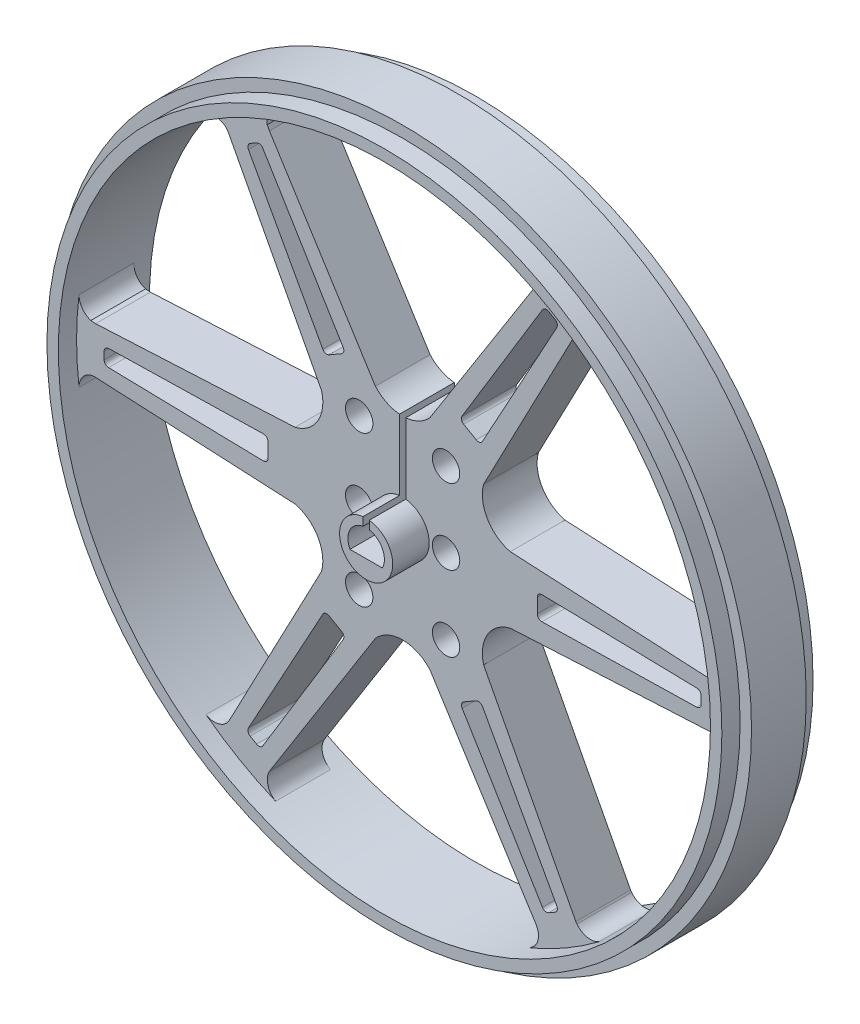
from build123d import *

# Parameters (mm, degrees)
Y_KSEKLIK_EKSTR_ZYON5_DEPTH      = 5
Y_KSEKLIK_EKSTR_ZYON5_DEPTH_BACK = 5
IZIM1_R                          = 37
Y_KSEKLIK_EKSTR_ZYON6_DEPTH      = 3
Y_KSEKLIK_EKSTR_ZYON6_DEPTH_BACK = 3
IZIM1_13_R                       = 38.25
IZIM1_13_R_2                     = 37
Y_KSEKLIK_EKSTR_ZYON7_DEPTH      = 3
Y_KSEKLIK_EKSTR_ZYON7_DEPTH_BACK = 3
IZIM1_14_R                       = 1.5
Y_KSEKLIK_EKSTR_ZYON8_DEPTH      = 7
Y_KSEKLIK_EKSTR_ZYON8_DEPTH_BACK = 3


with BuildPart() as part:
    # Çizim1 → Yükseklik-Ekstrüzyon5 (new, two sides: drawn at the far end of the back side and taken through both)
    with BuildSketch(Plane.XY.offset(-Y_KSEKLIK_EKSTR_ZYON5_DEPTH_BACK)):
        Circle(IZIM1_R)
        with BuildLine():
            ThreePointArc((-13.92488883, 32.926584565), (0, 35.75), (13.92488883, 32.926584565))
            ThreePointArc((13.92488883, 32.926584565), (17.875, 30.960408185), (21.552814278, 28.522599754))
            ThreePointArc((21.552814278, 28.522599754), (30.960408185, 17.875), (35.477703108, 4.403984811))
            ThreePointArc((35.477703108, 4.403984811), (35.681860841, 2.206197397), (35.75, 0))
            ThreePointArc((35.75, 0), (35.681860841, -2.206197397), (35.477703108, -4.403984811))
            ThreePointArc((35.477703108, -4.403984811), (30.960408185, -17.875), (21.552814278, -28.522599754))
            ThreePointArc((21.552814278, -28.522599754), (17.875, -30.960408185), (13.92488883, -32.926584565))
            ThreePointArc((13.92488883, -32.926584565), (0, -35.75), (-13.92488883, -32.926584565))
            ThreePointArc((-13.92488883, -32.926584565), (-17.875, -30.960408185), (-21.552814278, -28.522599754))
            ThreePointArc((-21.552814278, -28.522599754), (-30.960408185, -17.875), (-35.477703108, -4.403984811))
            ThreePointArc((-35.477703108, -4.403984811), (-35.75, 0), (-35.477703108, 4.403984811))
            ThreePointArc((-35.477703108, 4.403984811), (-30.960408185, 17.875), (-21.552814278, 28.522599754))
            ThreePointArc((-21.552814278, 28.522599754), (-17.875, 30.960408185), (-13.92488883, 32.926584565))
        make_face(mode=Mode.SUBTRACT)
    extrude(amount=Y_KSEKLIK_EKSTR_ZYON5_DEPTH + Y_KSEKLIK_EKSTR_ZYON5_DEPTH_BACK)

    # Çizim1<13> → Yükseklik-Ekstrüzyon6 (add, two sides: drawn at the far end of the back side and taken through both)
    with BuildSketch(Plane.XY.offset(-Y_KSEKLIK_EKSTR_ZYON6_DEPTH_BACK)):
        Circle(IZIM1_13_R)
        Circle(IZIM1_13_R_2, mode=Mode.SUBTRACT)
    extrude(amount=Y_KSEKLIK_EKSTR_ZYON6_DEPTH + Y_KSEKLIK_EKSTR_ZYON6_DEPTH_BACK)

    # Çizim1<14> → Yükseklik-Ekstrüzyon7 (add, two sides: drawn at the far end of the back side and taken through both)
    with BuildSketch(Plane.XY.offset(-Y_KSEKLIK_EKSTR_ZYON7_DEPTH_BACK)):
        with BuildLine():
            Line((0.345332455, 10.619791473), (0.345332455, 8.211364581))
            Line((0.345332455, 8.211364581), (0.345332455, 2.892483792))
            ThreePointArc((0.345332455, 2.892483792), (2.178494802, 1.93387626), (2.913025402, 0))
            ThreePointArc((2.913025402, 0), (-1.934432099, -2.17800125), (-0.343856219, 2.892659657))
            Line((-0.343856219, 2.892659657), (-0.341141708, 8.211536302))
            Line((-0.341141708, 8.211536302), (-0.339912555, 10.619966332))
            ThreePointArc((-0.339912555, 10.619966332), (-1.789622614, 11.029720322), (-2.984950797, 11.946643504))
            Line((-2.984950797, 11.946643504), (-14.607897055, 30.387938553))
            Line((-14.607897055, 30.387938553), (-14.847878363, 30.848411366))
            ThreePointArc((-14.847878363, 30.848411366), (-14.740281438, 32.044676397), (-13.92488883, 32.926584565))
            ThreePointArc((-13.92488883, 32.926584565), (-17.875, 30.960408185), (-21.552814278, 28.522599754))
            ThreePointArc((-21.552814278, 28.522599754), (-20.401800041, 28.78442387), (-19.324525803, 28.301862102))
            Line((-19.324525803, 28.301862102), (-19.045735303, 27.863795787))
            Line((-19.045735303, 27.863795787), (-8.886868167, 8.577081355))
            ThreePointArc((-8.886868167, 8.577081355), (-9.303777514, 5.496482546), (-11.800782256, 3.644761794))
            Line((-11.800782256, 3.644761794), (-33.653555768, 2.549643924))
            Line((-33.653555768, 2.549643924), (-34.19029782, 2.590308308))
            ThreePointArc((-34.19029782, 2.590308308), (-35.134400226, 3.283913251), (-35.477703108, 4.403984811))
            ThreePointArc((-35.477703108, 4.403984811), (-35.75, 0), (-35.477703108, -4.403984811))
            ThreePointArc((-35.477703108, -4.403984811), (-35.134400226, -3.283913251), (-34.19029782, -2.590308308))
            Line((-34.19029782, -2.590308308), (-33.653555768, -2.549643924))
            Line((-33.653555768, -2.549643924), (-11.802585687, -3.638917628))
            ThreePointArc((-11.802585687, -3.638917628), (-9.303458853, -5.492132995), (-8.888309481, -8.575587733))
            Line((-8.888309481, -8.575587733), (-19.045735303, -27.863795787))
            ThreePointArc((-19.045735303, -27.863795787), (-20.165883221, -28.700819486), (-21.552814278, -28.522599754))
            ThreePointArc((-21.552814278, -28.522599754), (-17.875, -30.960408185), (-13.92488883, -32.926584565))
            ThreePointArc((-13.92488883, -32.926584565), (-14.772697173, -31.814576902), (-14.607887345, -30.4259885))
            Line((-14.607887345, -30.4259885), (-2.984941087, -11.98469345))
            ThreePointArc((-2.984941087, -11.98469345), (0.002715908, -10.643228062), (2.991057136, -11.983168513))
            Line((2.991057136, -11.983168513), (14.663708375, -30.397995932))
            ThreePointArc((14.663708375, -30.397995932), (14.817986455, -31.815304786), (13.92488883, -32.926584565))
            ThreePointArc((13.92488883, -32.926584565), (17.875, -30.960408185), (21.552814278, -28.522599754))
            ThreePointArc((21.552814278, -28.522599754), (20.242255546, -28.76161283), (19.107217792, -28.064202809))
            Line((19.107217792, -28.064202809), (18.993975038, -27.89787469))
            Line((18.993975038, -27.89787469), (8.881942007, -8.582182507))
            ThreePointArc((8.881942007, -8.582182507), (9.294710999, -5.488602486), (11.804336715, -3.633233425))
            Line((11.804336715, -3.633233425), (33.657290889, -2.499854))
            Line((33.657290889, -2.499854), (33.849149755, -2.514104082))
            ThreePointArc((33.849149755, -2.514104082), (35.026532395, -3.146147751), (35.477703108, -4.403984811))
            ThreePointArc((35.477703108, -4.403984811), (35.681860841, -2.206197397), (35.75, 0))
            ThreePointArc((35.75, 0), (35.681860841, 2.206197397), (35.477703108, 4.403984811))
            ThreePointArc((35.477703108, 4.403984811), (35.026532395, 3.146147751), (33.849149755, 2.514104082))
            Line((33.849149755, 2.514104082), (33.657290889, 2.499854))
            Line((33.657290889, 2.499854), (11.803877394, 3.634725418))
            ThreePointArc((11.803877394, 3.634725418), (9.295867667, 5.489285508), (8.88302669, 8.581059795))
            Line((8.88302669, 8.581059795), (18.993975038, 27.89787469))
            Line((18.993975038, 27.89787469), (18.993582514, 27.898141932))
            ThreePointArc((18.993582514, 27.898141932), (20.143868947, 28.740405096), (21.552814278, 28.522599754))
            ThreePointArc((21.552814278, 28.522599754), (17.875, 30.960408185), (13.92488883, 32.926584565))
            ThreePointArc((13.92488883, 32.926584565), (14.836394127, 31.799309486), (14.663698665, 30.359945986))
            Line((14.663698665, 30.359945986), (14.663270965, 30.360152301))
            Line((14.663270965, 30.360152301), (2.991047427, 11.945118566))
            ThreePointArc((2.991047427, 11.945118566), (1.795251444, 11.028805544), (0.345332455, 10.619791473))
        make_face()
        with BuildLine():
            ThreePointArc((-15.330091906, -28.374268836), (-15.633406502, -28.599064993), (-16.007432074, -28.547704226))
            Line((-16.007432074, -28.547704226), (-16.719321042, -28.136694938))
            ThreePointArc((-16.719321042, -28.136694938), (-16.950813558, -27.838459675), (-16.907791673, -27.46338345))
            Line((-16.907791673, -27.46338345), (-8.752791972, -12.583042517))
            ThreePointArc((-8.752791972, -12.583042517), (-8.44909878, -12.341848787), (-8.064321341, -12.3903286))
            Line((-8.064321341, -12.3903286), (-6.698178659, -13.179071446))
            ThreePointArc((-6.698178659, -13.179071446), (-6.463805189, -13.488058576), (-6.52083849, -13.87166146))
            Line((-6.52083849, -13.87166146), (-15.330091906, -28.374268836))
        make_face(mode=Mode.SUBTRACT)
        with Locations((-4.7625, -8.25)):
            Circle(IZIM1_14_R, mode=Mode.SUBTRACT)
        with BuildLine():
            Line((16.719321042, -28.136694938), (16.007432074, -28.547704226))
            ThreePointArc((16.007432074, -28.547704226), (15.633406502, -28.599064993), (15.330091906, -28.374268836))
            Line((15.330091906, -28.374268836), (6.52083849, -13.87166146))
            ThreePointArc((6.52083849, -13.87166146), (6.463805189, -13.488058576), (6.698178659, -13.179071446))
            Line((6.698178659, -13.179071446), (8.064321341, -12.3903286))
            ThreePointArc((8.064321341, -12.3903286), (8.44909878, -12.341848787), (8.752791972, -12.583042517))
            Line((8.752791972, -12.583042517), (16.907791673, -27.46338345))
            ThreePointArc((16.907791673, -27.46338345), (16.950813558, -27.838459675), (16.719321042, -28.136694938))
        make_face(mode=Mode.SUBTRACT)
        with Locations((4.7625, -8.25)):
            Circle(IZIM1_14_R, mode=Mode.SUBTRACT)
        with BuildLine():
            Line((-32.726753116, -0.411009288), (-32.726753116, 0.411009288))
            ThreePointArc((-32.726753116, 0.411009288), (-32.584220059, 0.760605318), (-32.237883578, 0.910885385))
            Line((-32.237883578, 0.910885385), (-15.273630462, 1.288618943))
            ThreePointArc((-15.273630462, 1.288618943), (-14.91290397, 1.146209789), (-14.7625, 0.788742846))
            Line((-14.7625, 0.788742846), (-14.7625, -0.788742846))
            ThreePointArc((-14.7625, -0.788742846), (-14.91290397, -1.146209789), (-15.273630462, -1.288618943))
            Line((-15.273630462, -1.288618943), (-32.237883578, -0.910885385))
            ThreePointArc((-32.237883578, -0.910885385), (-32.584220059, -0.760605318), (-32.726753116, -0.411009288))
        make_face(mode=Mode.SUBTRACT)
        with Locations((-4.7625, 0)):
            Circle(IZIM1_14_R, mode=Mode.SUBTRACT)
        with Locations((-4.7625, 8.25)):
            Circle(IZIM1_14_R, mode=Mode.SUBTRACT)
        with BuildLine():
            ThreePointArc((-6.52083849, 13.87166146), (-6.463805189, 13.488058576), (-6.698178659, 13.179071446))
            Line((-6.698178659, 13.179071446), (-8.064321341, 12.3903286))
            ThreePointArc((-8.064321341, 12.3903286), (-8.44909878, 12.341848787), (-8.752791972, 12.583042517))
            Line((-8.752791972, 12.583042517), (-16.907791673, 27.46338345))
            ThreePointArc((-16.907791673, 27.46338345), (-16.950813558, 27.838459675), (-16.719321042, 28.136694938))
            Line((-16.719321042, 28.136694938), (-16.007432074, 28.547704226))
            ThreePointArc((-16.007432074, 28.547704226), (-15.633406502, 28.599064993), (-15.330091906, 28.374268836))
            Line((-15.330091906, 28.374268836), (-6.52083849, 13.87166146))
        make_face(mode=Mode.SUBTRACT)
        with Locations((4.7625, 0)):
            Circle(IZIM1_14_R, mode=Mode.SUBTRACT)
        with Locations((4.7625, 8.25)):
            Circle(IZIM1_14_R, mode=Mode.SUBTRACT)
        with BuildLine():
            ThreePointArc((32.237883578, 0.910885385), (32.584220059, 0.760605318), (32.726753116, 0.411009288))
            Line((32.726753116, 0.411009288), (32.726753116, -0.411009288))
            ThreePointArc((32.726753116, -0.411009288), (32.584220059, -0.760605318), (32.237883578, -0.910885385))
            Line((32.237883578, -0.910885385), (15.273630462, -1.288618943))
            ThreePointArc((15.273630462, -1.288618943), (14.91290397, -1.146209789), (14.7625, -0.788742846))
            Line((14.7625, -0.788742846), (14.7625, 0.788742846))
            ThreePointArc((14.7625, 0.788742846), (14.91290397, 1.146209789), (15.273630462, 1.288618943))
            Line((15.273630462, 1.288618943), (32.237883578, 0.910885385))
        make_face(mode=Mode.SUBTRACT)
        with BuildLine():
            Line((8.064321341, 12.3903286), (6.698178659, 13.179071446))
            ThreePointArc((6.698178659, 13.179071446), (6.463805189, 13.488058576), (6.52083849, 13.87166146))
            Line((6.52083849, 13.87166146), (15.330091906, 28.374268836))
            ThreePointArc((15.330091906, 28.374268836), (15.633406502, 28.599064993), (16.007432074, 28.547704226))
            Line((16.007432074, 28.547704226), (16.719321042, 28.136694938))
            ThreePointArc((16.719321042, 28.136694938), (16.950813558, 27.838459675), (16.907791673, 27.46338345))
            Line((16.907791673, 27.46338345), (8.752791972, 12.583042517))
            ThreePointArc((8.752791972, 12.583042517), (8.44909878, 12.341848787), (8.064321341, 12.3903286))
        make_face(mode=Mode.SUBTRACT)
    extrude(amount=Y_KSEKLIK_EKSTR_ZYON7_DEPTH + Y_KSEKLIK_EKSTR_ZYON7_DEPTH_BACK)

    # Çizim1<17> → Yükseklik-Ekstrüzyon8 (add, two sides: drawn at the far end of the back side and taken through both)
    with BuildSketch(Plane.XY.offset(-Y_KSEKLIK_EKSTR_ZYON8_DEPTH_BACK)):
        with BuildLine():
            ThreePointArc((2.913025402, 0), (2.178494802, 1.93387626), (0.345332455, 2.892483792))
            Line((0.345332455, 2.892483792), (0.345332455, 1.969960785))
            ThreePointArc((0.345332455, 1.969960785), (1.794746568, 0.882544479), (1.770998825, -0.929280992))
            Line((1.770998825, -0.929280992), (-1.770998825, -0.929280992))
            ThreePointArc((-1.770998825, -0.929280992), (-1.794521304, 0.883002429), (-0.344327032, 1.970136771))
            Line((-0.344327032, 1.970136771), (-0.343856219, 2.892659657))
            ThreePointArc((-0.343856219, 2.892659657), (-1.934432099, -2.17800125), (2.913025402, 0))
        make_face()
    extrude(amount=Y_KSEKLIK_EKSTR_ZYON8_DEPTH + Y_KSEKLIK_EKSTR_ZYON8_DEPTH_BACK)


solid = part.part
